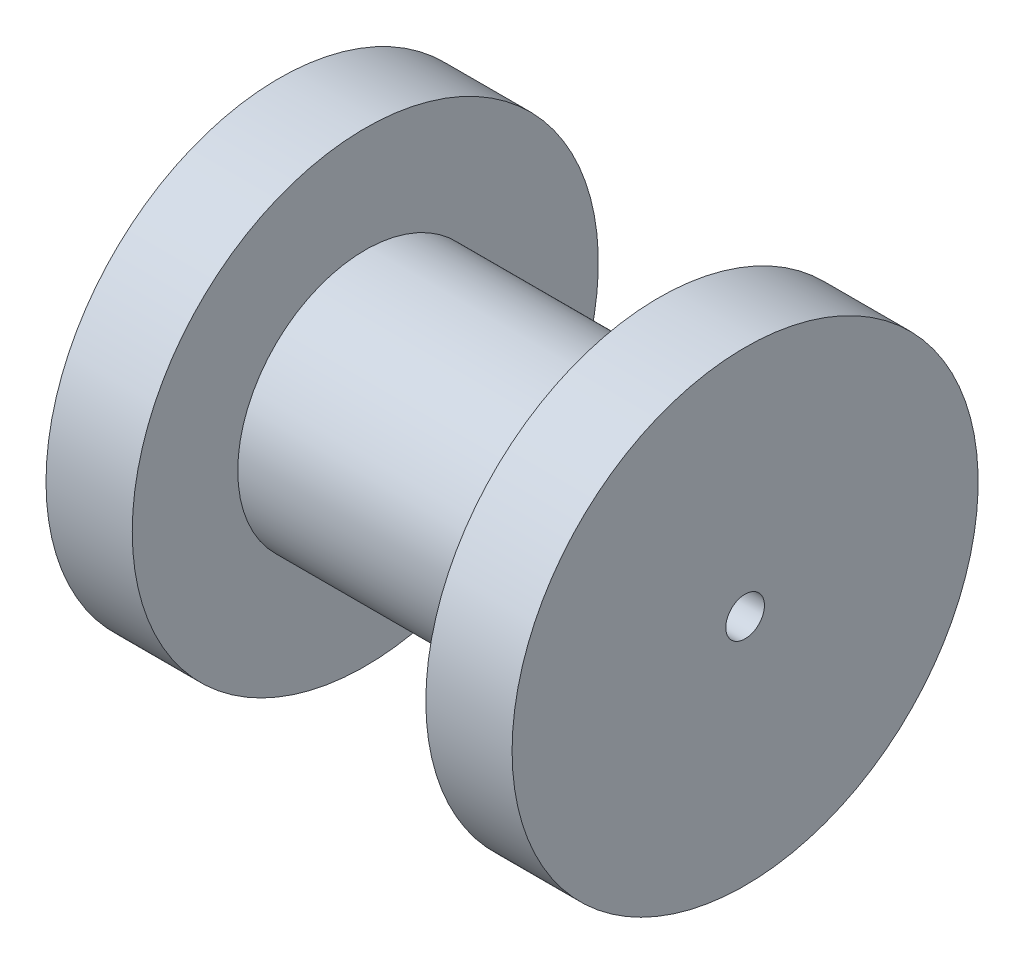
from build123d import *


with BuildPart() as part:
    # Sketch2 → Revolve1 (revolve)
    with BuildSketch(Plane(origin=(0, 0, 0), x_dir=(1, 0, 0), z_dir=(0, 1, 0))):
        Polygon((8, -12.7), (12.7, -12.7), (12.7, -1.0541), (-12.7, -1.0541), (-12.7, -12.7), (-8, -12.7), (-8, -6.95), (8, -6.95), align=None)
    revolve(axis=Axis((0, 0, 0), (1, 0, 0)))


solid = part.part
